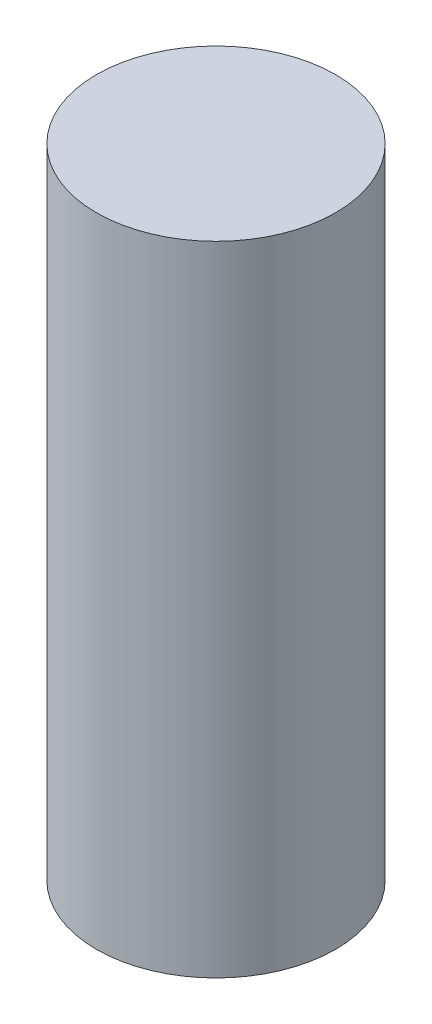
from build123d import *

# Parameters (mm, degrees)
SKETCH1_R           = 4.7625
BOSS_EXTRUDE1_DEPTH = 25.4


with BuildPart() as part:
    # Sketch1 → Boss-Extrude1 (new body)
    with BuildSketch(Plane(origin=(0, 0, 0), x_dir=(1, 0, 0), z_dir=(0, 1, 0))):
        Circle(SKETCH1_R)
    extrude(amount=BOSS_EXTRUDE1_DEPTH)


solid = part.part
